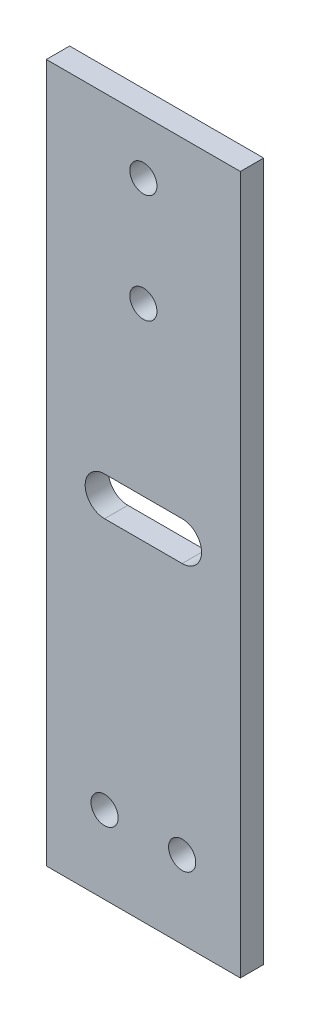
from build123d import *

# Parameters (mm, degrees)
SKETCH_1_W          = 25
SKETCH_1_H          = 90
EXTRUDE_1_DEPTH     = 3
SKETCH_3_R          = 1.75
CUT_EXTRUDE_1_DEPTH = 4
CUT_EXTRUDE_2_DEPTH = 4


with BuildPart() as part:
    # 草图1 → 凸台-拉伸1 (new body)
    with BuildSketch(Plane.XY):
        Rectangle(SKETCH_1_W, SKETCH_1_H)
    extrude(amount=EXTRUDE_1_DEPTH)

    # 草图3 → 切除-拉伸1 (cut, through all)
    with BuildSketch(Plane.XY.offset(3)):
        with Locations((0, 38)):
            Circle(SKETCH_3_R)
        with Locations((0, 24)):
            Circle(SKETCH_3_R)
        with Locations((-5, -35)):
            Circle(SKETCH_3_R)
        with Locations((5, -35)):
            Circle(SKETCH_3_R)
    extrude(amount=-CUT_EXTRUDE_1_DEPTH, mode=Mode.SUBTRACT)

    # 草图4 → 切除-拉伸2 (cut, through all)
    with BuildSketch(Plane.XY.offset(3)):
        with BuildLine():
            Line((-5, 2.5), (5, 2.5))
            ThreePointArc((5, 2.5), (7.5, 0), (5, -2.5))
            Line((5, -2.5), (-5, -2.5))
            ThreePointArc((-5, -2.5), (-7.5, 0), (-5, 2.5))
        make_face()
    extrude(amount=-CUT_EXTRUDE_2_DEPTH, mode=Mode.SUBTRACT)


solid = part.part
